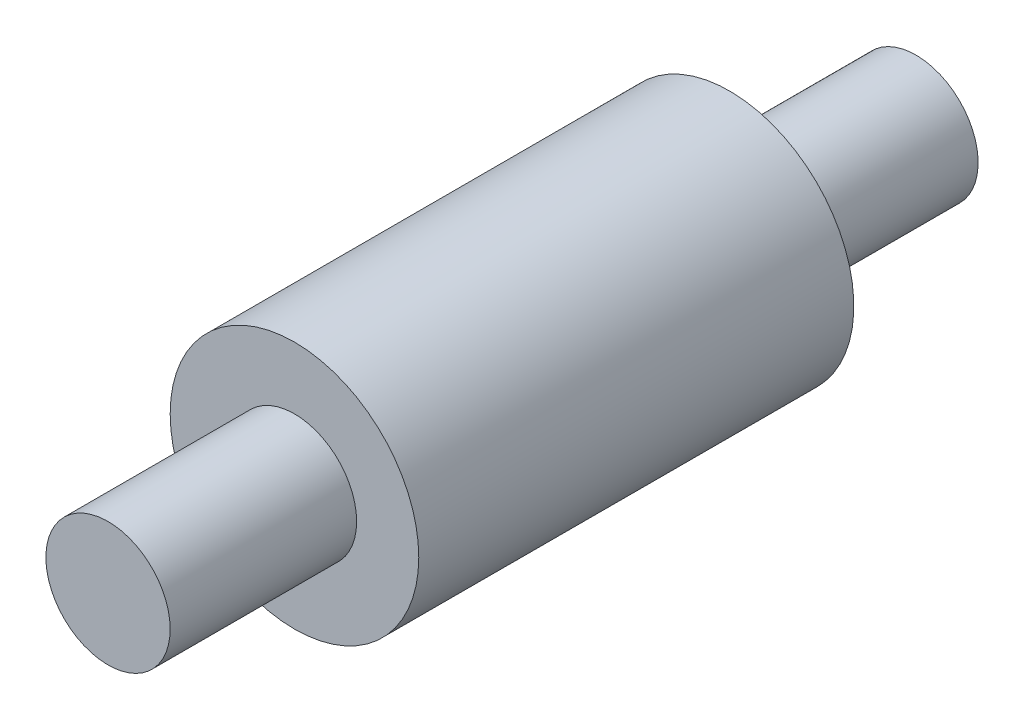
from build123d import *

# Parameters (mm, degrees)
SKETCH2_R           = 20
BOSS_EXTRUDE4_DEPTH = 130
SKETCH3_OUTSIDE_W   = 70.354
SKETCH3_OUTSIDE_H   = 70.354
SKETCH3_OUTSIDE_R   = 10
CUT_EXTRUDE1_DEPTH  = 30
SKETCH4_OUTSIDE_W   = 70.354
SKETCH4_OUTSIDE_H   = 70.354
SKETCH4_OUTSIDE_R   = 10
CUT_EXTRUDE2_DEPTH  = 30


with BuildPart() as part:
    # Sketch2 → Boss-Extrude4 (new body)
    with BuildSketch(Plane.XY):
        Circle(SKETCH2_R)
    extrude(amount=BOSS_EXTRUDE4_DEPTH)

    # Sketch3 outside → Cut-Extrude1 (cut)
    with BuildSketch(Plane.XY.offset(130)):
        Rectangle(SKETCH3_OUTSIDE_W, SKETCH3_OUTSIDE_H)
        Circle(SKETCH3_OUTSIDE_R, mode=Mode.SUBTRACT)
    extrude(amount=-CUT_EXTRUDE1_DEPTH, mode=Mode.SUBTRACT)

    # Sketch4 outside → Cut-Extrude2 (cut)
    with BuildSketch(Plane(origin=(0, 0, 0), x_dir=(-1, 0, 0), z_dir=(0, 0, -1))):
        Rectangle(SKETCH4_OUTSIDE_W, SKETCH4_OUTSIDE_H)
        Circle(SKETCH4_OUTSIDE_R, mode=Mode.SUBTRACT)
    extrude(amount=-CUT_EXTRUDE2_DEPTH, mode=Mode.SUBTRACT)


solid = part.part
